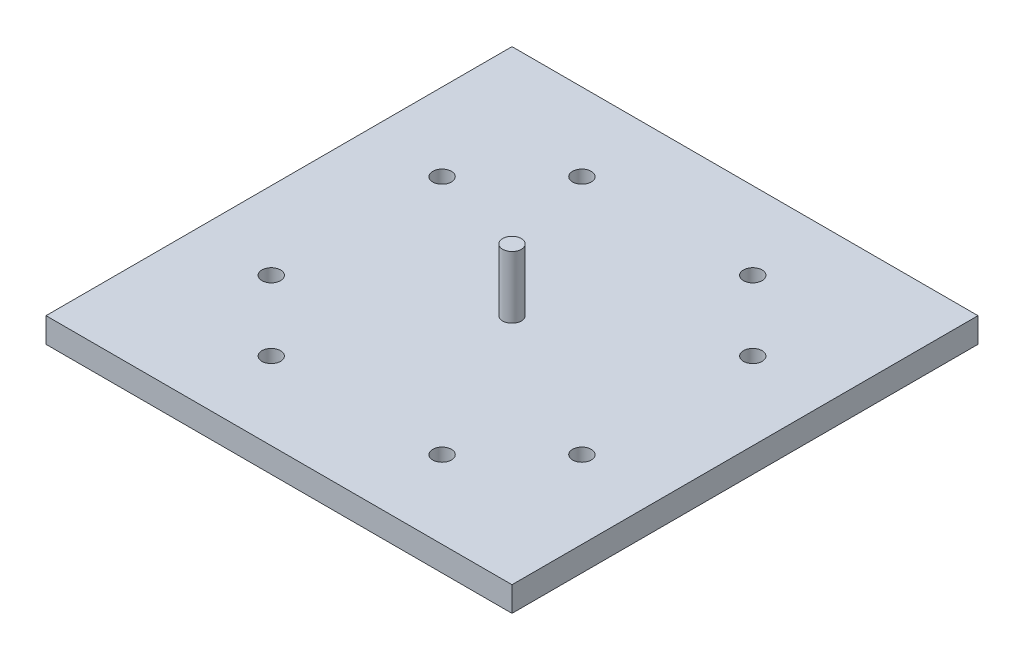
from build123d import *

# Parameters (mm, degrees)
SKETCH1_W           = 30
SKETCH1_H           = 30
BOSS_EXTRUDE1_DEPTH = 1.6
SKETCH2_R           = 0.6
CUT_EXTRUDE1_DEPTH  = 1.6
CIRPATTERN1_COUNT   = 2
CIRPATTERN1_ANGLE   = 90
SKETCH4_R           = 0.6
BOSS_EXTRUDE2_DEPTH = 4


with BuildPart() as part:
    # Sketch1 → Boss-Extrude1 (new body)
    with BuildSketch(Plane(origin=(0, 0, 0), x_dir=(1, 0, 0), z_dir=(0, 1, 0))):
        with Locations((15, 15)):
            Rectangle(SKETCH1_W, SKETCH1_H)
    extrude(amount=BOSS_EXTRUDE1_DEPTH)

    # Sketch2 → Cut-Extrude1 (cut)
    with BuildSketch(Plane(origin=(0, 1.6, 0), x_dir=(1, 0, 0), z_dir=(0, 1, 0))):
        with Locations((20.5, 5)):
            Circle(SKETCH2_R)
        with Locations((9.5, 5)):
            Circle(SKETCH2_R)
        with Locations((20.5, 25)):
            Circle(SKETCH2_R)
        with Locations((9.5, 25)):
            Circle(SKETCH2_R)
    cut_extrude1 = extrude(amount=-CUT_EXTRUDE1_DEPTH, mode=Mode.SUBTRACT)

    # CirPattern1: Cut-Extrude1 ×2 about axis
    cirpattern1_axis = Axis((15, 0, -15), (0, 1, 0))
    for i in range(1, CIRPATTERN1_COUNT):
        add(cut_extrude1.rotate(cirpattern1_axis, i * CIRPATTERN1_ANGLE / (CIRPATTERN1_COUNT - 1)), mode=Mode.SUBTRACT)

    # Sketch4 → Boss-Extrude2 (add)
    with BuildSketch(Plane(origin=(0, 1.6, 0), x_dir=(1, 0, 0), z_dir=(0, 1, 0))):
        with Locations((15, 15)):
            Circle(SKETCH4_R)
    extrude(amount=BOSS_EXTRUDE2_DEPTH)


solid = part.part
